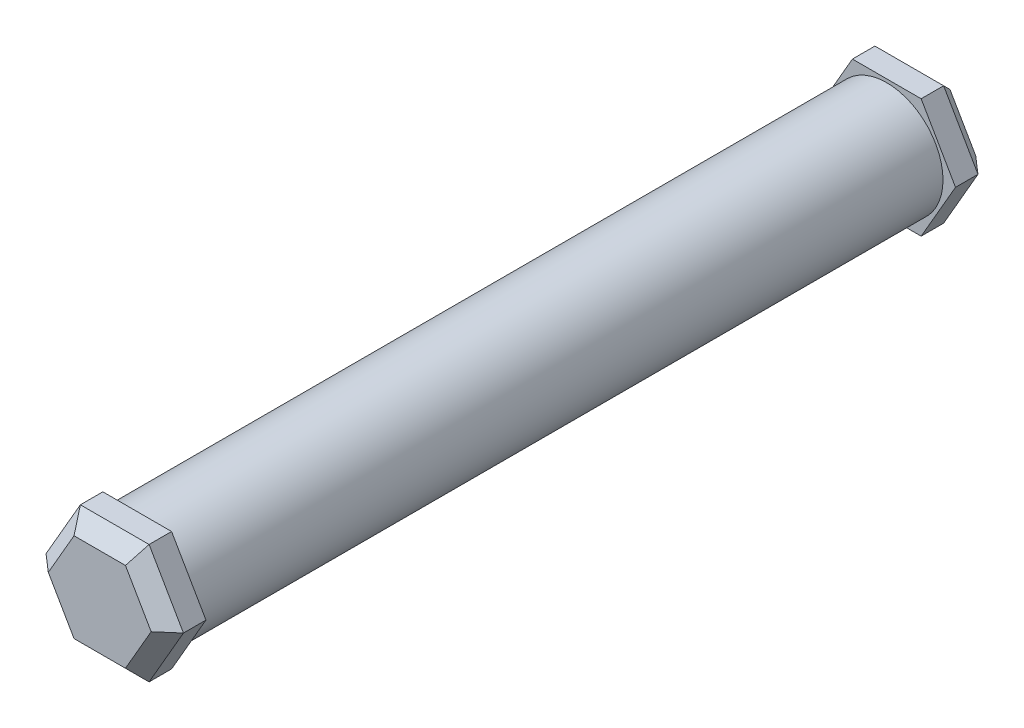
from build123d import *

# Parameters (mm, degrees)
SKETCH1_R           = 15
BOSS_EXTRUDE1_DEPTH = 200
BOSS_EXTRUDE2_DEPTH = 10
BOSS_EXTRUDE3_DEPTH = 10
CHAMFER1_SIZE       = 4


with BuildPart() as part:
    # Sketch1 → Boss-Extrude1 (new body)
    with BuildSketch(Plane.XY):
        Circle(SKETCH1_R)
    extrude(amount=BOSS_EXTRUDE1_DEPTH)

    # Sketch3 → Boss-Extrude2 (add)
    with BuildSketch(Plane(origin=(0, 0, 0), x_dir=(-1, 0, 0), z_dir=(0, 0, -1))):
        Polygon((18.338660343, 0), (9.169330171, 15.881745728), (-9.169330171, 15.881745728), (-18.338660343, 0), (-9.169330171, -15.881745728), (9.169330171, -15.881745728), align=None)
    extrude(amount=BOSS_EXTRUDE2_DEPTH)

    # Sketch2 → Boss-Extrude3 (add)
    with BuildSketch(Plane.XY.offset(200)):
        Polygon((18.338660343, 0), (9.169330171, 15.881745728), (-9.169330171, 15.881745728), (-18.338660343, 0), (-9.169330171, -15.881745728), (9.169330171, -15.881745728), align=None)
    extrude(amount=BOSS_EXTRUDE3_DEPTH)

    # Chamfer1
    chamfer1_edges = [part.edges().sort_by_distance(p)[0] for p in [
        (13.753995257, -7.940872864, 210),
        (13.753995257, 7.940872864, 210),
        (0, 15.881745728, 210),
        (-13.753995257, 7.940872864, 210),
        (-13.753995257, -7.940872864, 210),
        (0, -15.881745728, 210),
        (-13.753995257, -7.940872864, -10),
        (-13.753995257, 7.940872864, -10),
        (0, 15.881745728, -10),
        (13.753995257, 7.940872864, -10),
        (13.753995257, -7.940872864, -10),
        (0, -15.881745728, -10),
    ]]
    chamfer(chamfer1_edges, length=CHAMFER1_SIZE)


solid = part.part
